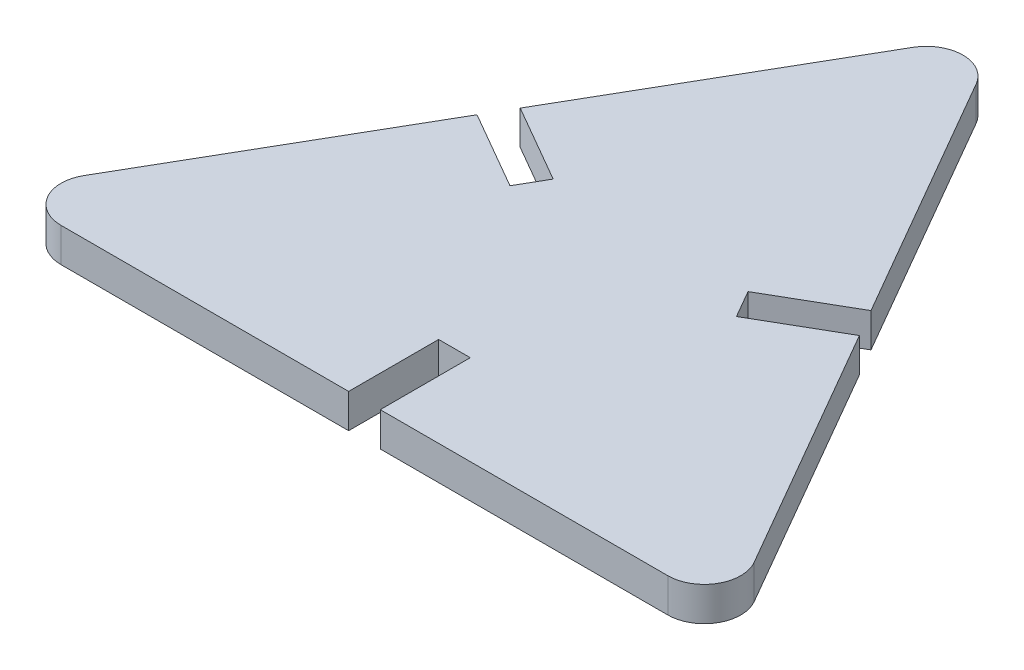
from build123d import *

# Parameters (mm, degrees)
BOSS_EXTRUDE1_DEPTH = 2.8


with BuildPart() as part:
    # Sketch1 → Boss-Extrude1 (new body)
    with BuildSketch(Plane(origin=(0, 0, 0), x_dir=(1, 0, 0), z_dir=(0, 1, 0))):
        with BuildLine():
            Line((1.3, -17.4), (24.941531629, -17.4))
            ThreePointArc((24.941531629, -17.4), (27.53960784, -15.9), (27.53960784, -12.9))
            Line((27.53960784, -12.9), (15.718842026, 7.574166975))
            Line((15.718842026, 7.574166975), (9.310254038, 3.874166975))
            Line((9.310254038, 3.874166975), (8.010254038, 6.125833025))
            Line((8.010254038, 6.125833025), (14.418842026, 9.825833025))
            Line((14.418842026, 9.825833025), (2.598076211, 30.3))
            ThreePointArc((2.598076211, 30.3), (0, 31.8), (-2.598076211, 30.3))
            Line((-2.598076211, 30.3), (-14.418842026, 9.825833025))
            Line((-14.418842026, 9.825833025), (-8.010254038, 6.125833025))
            Line((-8.010254038, 6.125833025), (-9.310254038, 3.874166975))
            Line((-9.310254038, 3.874166975), (-15.718842026, 7.574166975))
            Line((-15.718842026, 7.574166975), (-27.53960784, -12.9))
            ThreePointArc((-27.53960784, -12.9), (-27.53960784, -15.9), (-24.941531629, -17.4))
            Line((-24.941531629, -17.4), (-1.3, -17.4))
            Line((-1.3, -17.4), (-1.3, -10))
            Line((-1.3, -10), (1.3, -10))
            Line((1.3, -10), (1.3, -17.4))
        make_face()
    extrude(amount=BOSS_EXTRUDE1_DEPTH)


solid = part.part
